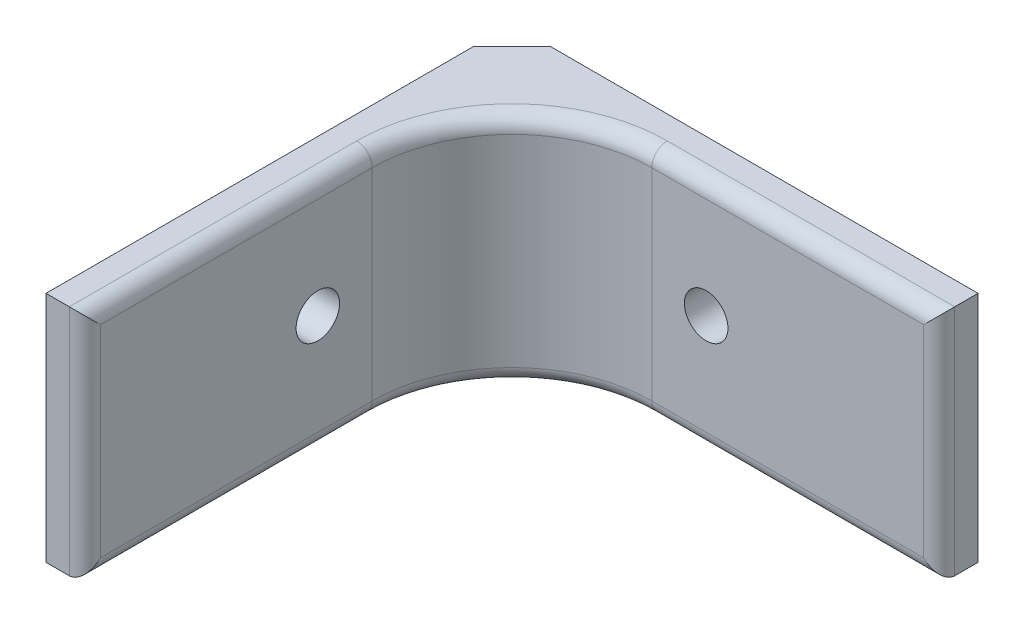
from build123d import *

# Parameters (mm, degrees)
BOSS_EXTRUDE1_DEPTH = 38.1
SKETCH2_R           = 3.556
CUT_EXTRUDE1_DEPTH  = 7.35
SKETCH3_R           = 3.556
CUT_EXTRUDE2_DEPTH  = 7.35
FILLET1_R           = 22.86
FILLET2_R           = 2.54
CHAMFER1_SIZE       = 6.35


with BuildPart() as part:
    # Sketch1 → Boss-Extrude1 (new body)
    with BuildSketch(Plane(origin=(0, 0, 0), x_dir=(1, 0, 0), z_dir=(0, 1, 0))):
        Polygon((0, 0), (0, -76.2), (6.35, -76.2), (6.35, -6.35), (76.2, -6.35), (76.2, 0), align=None)
    extrude(amount=BOSS_EXTRUDE1_DEPTH)

    # Sketch2 → Cut-Extrude1 (cut, through all)
    with BuildSketch(Plane(origin=(6.35, 0, 0), x_dir=(0, 0, -1), z_dir=(1, 0, 0))):
        with Locations((-38.1, 19.05)):
            Circle(SKETCH2_R)
    extrude(amount=-CUT_EXTRUDE1_DEPTH, mode=Mode.SUBTRACT)

    # Sketch3 → Cut-Extrude2 (cut, through all)
    with BuildSketch(Plane.XY.offset(6.35)):
        with Locations((38.1, 19.05)):
            Circle(SKETCH3_R)
    extrude(amount=-CUT_EXTRUDE2_DEPTH, mode=Mode.SUBTRACT)

    # Fillet1
    fillet1_edges = [part.edges().sort_by_distance(p)[0] for p in [
        (6.35, 19.05, 6.35),
    ]]
    fillet(fillet1_edges, radius=FILLET1_R)

    # Fillet2
    fillet2_edges = [part.edges().sort_by_distance(p)[0] for p in [
        (76.2, 19.05, 6.35),
        (6.35, 19.05, 76.2),
        (6.35, 38.1, 52.705),
        (52.705, 0, 6.35),
        (52.705, 38.1, 6.35),
        (13.045538982, 0, 13.045538982),
        (13.045538982, 38.1, 13.045538982),
        (6.35, 0, 52.705),
    ]]
    fillet(fillet2_edges, radius=FILLET2_R)

    # Chamfer1
    chamfer1_edges = [part.edges().sort_by_distance(p)[0] for p in [
        (0, 19.05, 0),
    ]]
    chamfer(chamfer1_edges, length=CHAMFER1_SIZE)


solid = part.part
